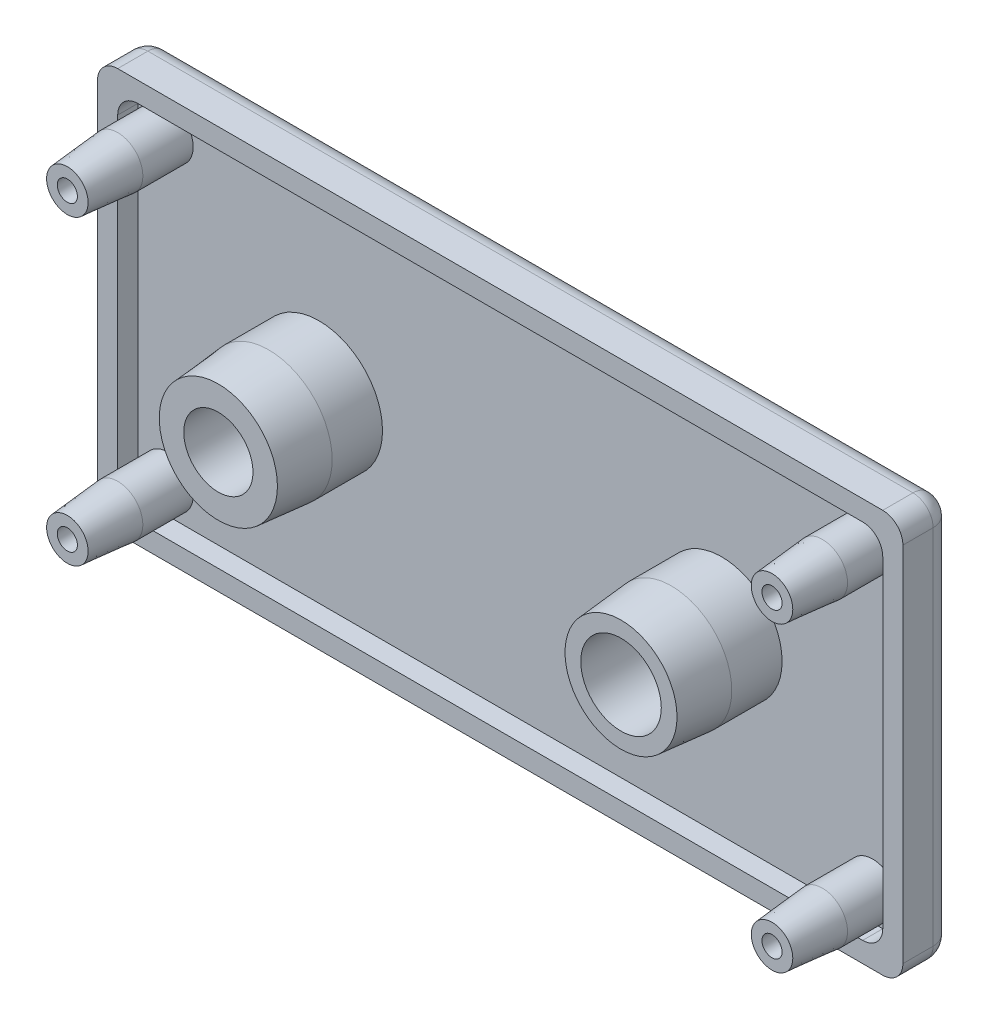
from build123d import *

# Parameters (mm, degrees)
SKETCH_1_W             = 80
SKETCH_1_H             = 40
EXTRUDE_1_DEPTH        = 5
FILLET_1_R             = 2
SKETCH_2_W             = 76
SKETCH_2_H             = 36
CUT_EXTRUDE_1_DEPTH    = 2
FILLET_2_R             = 2
FILLET_3_R             = 2
SKETCH_3_R             = 2.5
SKETCH_3_R_2           = 1
SKETCH_3_R_3           = 6
SKETCH_3_R_4           = 4
EXTRUDE_2_DEPTH        = 10
CHAMFER_1_SIZE         = 5
CHAMFER_1_SIZE2        = 0.437443318
SKETCH_4_R             = 6.306678775
SKETCH_4_R_2           = 3.438504878
EXTRUDE_3_DEPTH        = 10
CHAMFER_2_SIZE         = 5
CHAMFER_2_SIZE2        = 0.437443318
CHAMFER_4_SIZE         = 5
CHAMFER_4_SIZE2        = 0.437443318
CHAMFER_4_PART_2_SIZE  = 5
CHAMFER_4_PART_2_SIZE2 = 0.437443318
CHAMFER_4_PART_3_SIZE  = 5
CHAMFER_4_PART_3_SIZE2 = 0.437443318
CHAMFER_4_PART_4_SIZE  = 5
CHAMFER_4_PART_4_SIZE2 = 0.437443318


with BuildPart() as part:
    # 草图1 → 拉伸1 (new body)
    with BuildSketch(Plane.XY):
        with Locations((-5.372486772, -0.096031746)):
            Rectangle(SKETCH_1_W, SKETCH_1_H)
    extrude(amount=EXTRUDE_1_DEPTH)

    # 圆角1
    fillet_1_edges = [part.edges().sort_by_distance(p)[0] for p in [
        (-45.372486772, 19.903968254, 2.5),
        (34.627513228, 19.903968254, 2.5),
        (34.627513228, -20.096031746, 2.5),
        (-45.372486772, -20.096031746, 2.5),
    ]]
    fillet(fillet_1_edges, radius=FILLET_1_R)

    # 草图2 → 切除-拉伸1 (cut)
    with BuildSketch(Plane.XY.offset(5)):
        with Locations((-5.372486772, -0.096031746)):
            Rectangle(SKETCH_2_W, SKETCH_2_H)
    extrude(amount=-CUT_EXTRUDE_1_DEPTH, mode=Mode.SUBTRACT)

    # 圆角2
    fillet_2_edges = [part.edges().sort_by_distance(p)[0] for p in [
        (-43.372486772, -18.096031746, 4),
        (-43.372486772, 17.903968254, 4),
        (32.627513228, 17.903968254, 4),
        (32.627513228, -18.096031746, 4),
    ]]
    fillet(fillet_2_edges, radius=FILLET_2_R)

    # 圆角3
    fillet_3_edges = [part.edges().sort_by_distance(p)[0] for p in [
        (-5.372486772, -20.096031746, 0),
        (-45.372486772, -0.096031746, 0),
        (-5.372486772, 19.903968254, 0),
        (34.627513228, -0.096031746, 0),
        (-44.786700335, 19.318181816, 0),
        (34.04172679, 19.318181816, 0),
        (34.04172679, -19.510245308, 0),
        (-44.786700335, -19.510245308, 0),
    ]]
    fillet(fillet_3_edges, radius=FILLET_3_R)

    # 草图3 → 拉伸2 (add)
    with BuildSketch(Plane.XY.offset(3)):
        with Locations((-40.372486772, 14.903968254)):
            Circle(SKETCH_3_R)
        with Locations((-40.372486772, 14.903968254)):
            Circle(SKETCH_3_R_2, mode=Mode.SUBTRACT)
        with Locations((29.627513228, 14.903968254)):
            Circle(SKETCH_3_R)
        with Locations((29.627513228, 14.903968254)):
            Circle(SKETCH_3_R_2, mode=Mode.SUBTRACT)
        with Locations((29.627513228, -15.096031746)):
            Circle(SKETCH_3_R)
        with Locations((29.627513228, -15.096031746)):
            Circle(SKETCH_3_R_2, mode=Mode.SUBTRACT)
        with Locations((-40.372486772, -15.096031746)):
            Circle(SKETCH_3_R)
        with Locations((-40.372486772, -15.096031746)):
            Circle(SKETCH_3_R_2, mode=Mode.SUBTRACT)
        with Locations((14.627513228, -0.096031746)):
            Circle(SKETCH_3_R_3)
        with Locations((14.627513228, -0.096031746)):
            Circle(SKETCH_3_R_4, mode=Mode.SUBTRACT)
    extrude(amount=EXTRUDE_2_DEPTH)

    # 倒角1
    chamfer_1_edges = [part.edges().sort_by_distance(p)[0] for p in [
        (8.627513228, -0.096031746, 13),
    ]]
    chamfer_1_side = [part.faces().sort_by_distance(p)[0] for p in [
        (8.627513228, -0.096031746, 8),
    ]]
    chamfer(chamfer_1_edges, length=CHAMFER_1_SIZE, length2=CHAMFER_1_SIZE2, reference=chamfer_1_side[0])

    # 草图4 → 拉伸3 (add)
    with BuildSketch(Plane.XY.offset(3)):
        with Locations((-25.372486772, -0.096031746)):
            Circle(SKETCH_4_R)
        with Locations((-25.372486772, -0.096031746)):
            Circle(SKETCH_4_R_2, mode=Mode.SUBTRACT)
    extrude(amount=EXTRUDE_3_DEPTH)

    # 倒角2
    chamfer_2_edges = [part.edges().sort_by_distance(p)[0] for p in [
        (-31.679165547, -0.096031746, 13),
    ]]
    chamfer_2_side = [part.faces().sort_by_distance(p)[0] for p in [
        (-31.679165547, -0.096031746, 8),
    ]]
    chamfer(chamfer_2_edges, length=CHAMFER_2_SIZE, length2=CHAMFER_2_SIZE2, reference=chamfer_2_side[0])

    # 倒角4
    chamfer_4_edges = [part.edges().sort_by_distance(p)[0] for p in [
        (-42.872486772, 14.903968254, 13),
    ]]
    chamfer_4_side = [part.faces().sort_by_distance(p)[0] for p in [
        (-42.872486772, 14.903968254, 8),
    ]]
    chamfer(chamfer_4_edges, length=CHAMFER_4_SIZE, length2=CHAMFER_4_SIZE2, reference=chamfer_4_side[0])

    # 倒角4 part 2
    chamfer_4_part_2_edges = [part.edges().sort_by_distance(p)[0] for p in [
        (27.127513228, 14.903968254, 13),
    ]]
    chamfer_4_part_2_side = [part.faces().sort_by_distance(p)[0] for p in [
        (27.127513228, 14.903968254, 8),
    ]]
    chamfer(chamfer_4_part_2_edges, length=CHAMFER_4_PART_2_SIZE, length2=CHAMFER_4_PART_2_SIZE2, reference=chamfer_4_part_2_side[0])

    # 倒角4 part 3
    chamfer_4_part_3_edges = [part.edges().sort_by_distance(p)[0] for p in [
        (27.127513228, -15.096031746, 13),
    ]]
    chamfer_4_part_3_side = [part.faces().sort_by_distance(p)[0] for p in [
        (27.127513228, -15.096031746, 8),
    ]]
    chamfer(chamfer_4_part_3_edges, length=CHAMFER_4_PART_3_SIZE, length2=CHAMFER_4_PART_3_SIZE2, reference=chamfer_4_part_3_side[0])

    # 倒角4 part 4
    chamfer_4_part_4_edges = [part.edges().sort_by_distance(p)[0] for p in [
        (-42.872486772, -15.096031746, 13),
    ]]
    chamfer_4_part_4_side = [part.faces().sort_by_distance(p)[0] for p in [
        (-42.872486772, -15.096031746, 8),
    ]]
    chamfer(chamfer_4_part_4_edges, length=CHAMFER_4_PART_4_SIZE, length2=CHAMFER_4_PART_4_SIZE2, reference=chamfer_4_part_4_side[0])


solid = part.part
